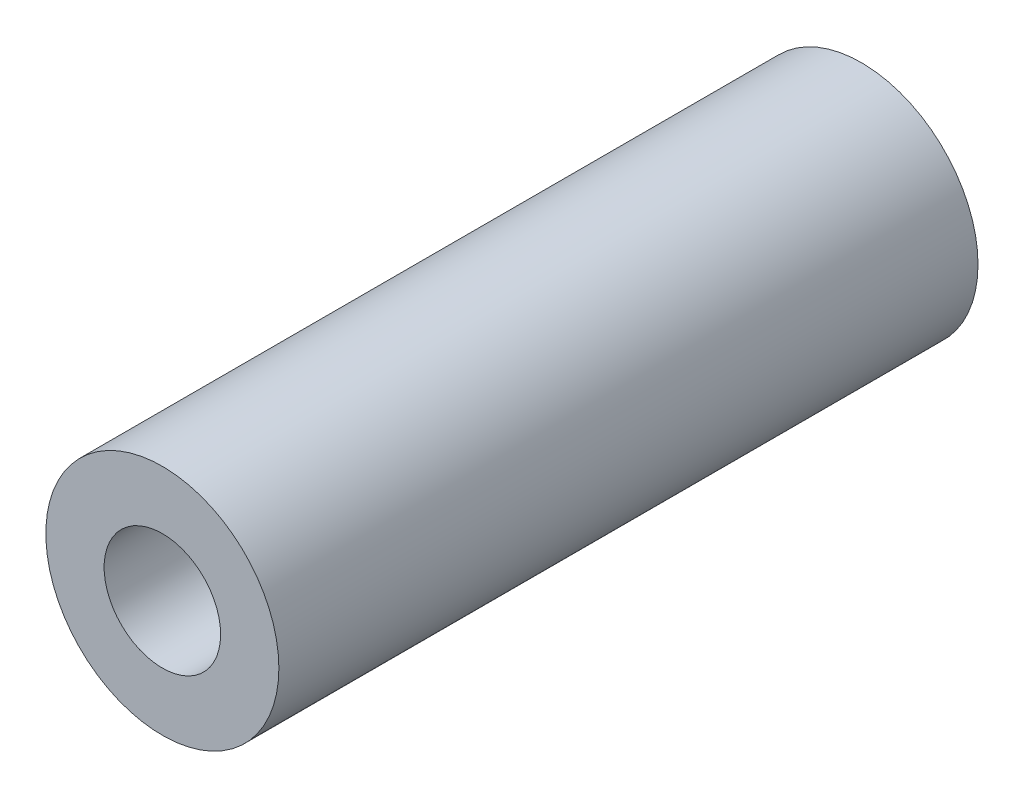
from build123d import *

# Parameters (mm, degrees)
SKETCH1_R           = 20
SKETCH1_R_2         = 10
BOSS_EXTRUDE1_DEPTH = 120


with BuildPart() as part:
    # Sketch1 → Boss-Extrude1 (new body)
    with BuildSketch(Plane.XY):
        Circle(SKETCH1_R)
        Circle(SKETCH1_R_2, mode=Mode.SUBTRACT)
    extrude(amount=BOSS_EXTRUDE1_DEPTH)


solid = part.part
